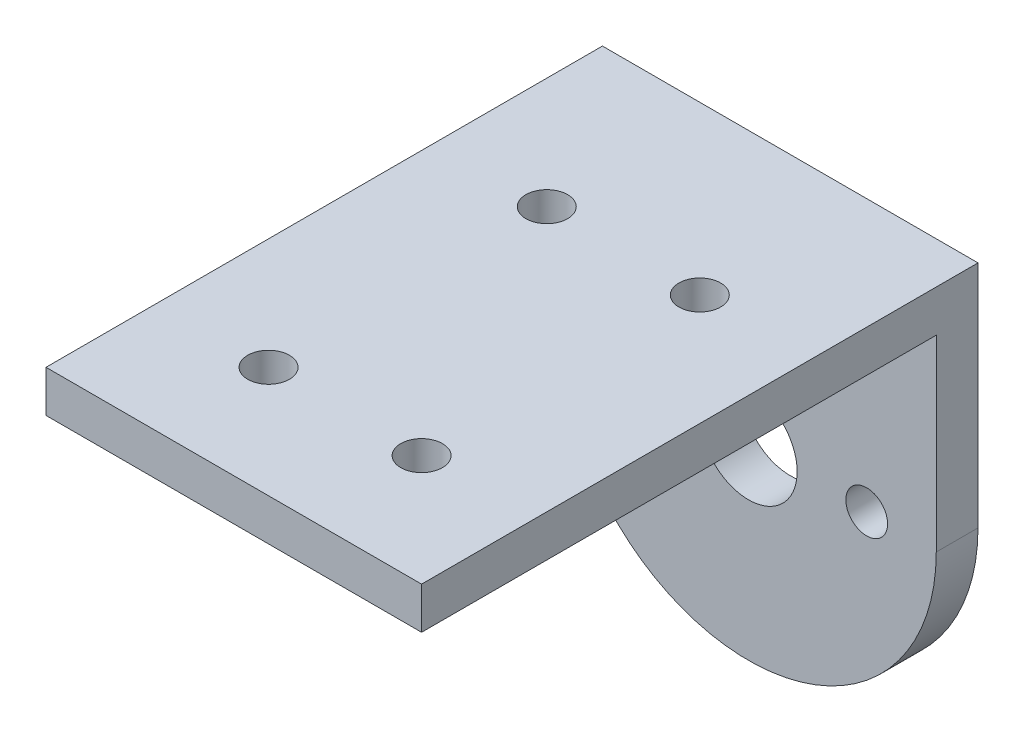
from build123d import *

# Parameters (mm, degrees)
MODEL_R             = 3.5
EXTRUDE_1_DEPTH     = 40
SKETCH_3_W          = 37
SKETCH_3_H          = 37
CUT_EXTRUDE_1_DEPTH = 40
SKETCH_4_R          = 1.5
CUT_EXTRUDE_2_DEPTH = 40
CUT_EXTRUDE1_REACH  = 42
SKETCH2_R           = 1.5


with BuildPart() as part:
    # Model → 凸台-拉伸1 (new body)
    with BuildSketch(Plane.XY):
        with BuildLine():
            Line((2619.766714505, 1592.826425633), (2619.766714505, 1609.326425633))
            Line((2619.766714505, 1609.326425633), (2592.766714505, 1609.326425633))
            Line((2592.766714505, 1609.326425633), (2592.766714505, 1592.826425633))
            ThreePointArc((2592.766714505, 1592.826425633), (2606.266714505, 1579.326425633), (2619.766714505, 1592.826425633))
        make_face()
        with Locations((2606.266714505, 1592.826425633)):
            Circle(MODEL_R, mode=Mode.SUBTRACT)
    extrude(amount=EXTRUDE_1_DEPTH)

    # 草图3 → 切除-拉伸1 (cut)
    with BuildSketch(Plane(origin=(2619.766714505, 0, 0), x_dir=(0, 0, -1), z_dir=(1, 0, 0))):
        with Locations((-21.5, 1587.826425633)):
            Rectangle(SKETCH_3_W, SKETCH_3_H)
    extrude(amount=-CUT_EXTRUDE_1_DEPTH, mode=Mode.SUBTRACT)

    # 草图4 → 切除-拉伸2 (cut)
    with BuildSketch(Plane(origin=(0, 1609.326425633, 0), x_dir=(1, 0, 0), z_dir=(0, 1, 0))):
        with Locations((2600.766714505, -32)):
            Circle(SKETCH_4_R)
        with Locations((2611.766714505, -32)):
            Circle(SKETCH_4_R)
        with Locations((2600.766714505, -12)):
            Circle(SKETCH_4_R)
        with Locations((2611.766714505, -12)):
            Circle(SKETCH_4_R)
    extrude(amount=-CUT_EXTRUDE_2_DEPTH, mode=Mode.SUBTRACT)

    # Sketch2 → Cut-Extrude1 (cut, up to next)
    with BuildSketch(Plane(origin=(0, 0, 0), x_dir=(-1, 0, 0), z_dir=(0, 0, -1)), mode=Mode.PRIVATE) as cut_extrude1_sk1:
        with Locations((-2597.766714505, 1592.826425633)):
            Circle(SKETCH2_R)
    cut_extrude1_tool1 = extrude(cut_extrude1_sk1.sketch, amount=-CUT_EXTRUDE1_REACH, mode=Mode.PRIVATE) & part.part
    add(cut_extrude1_tool1.solids().sort_by_distance((2597.766715, 1592.826426, 0))[0], mode=Mode.SUBTRACT)
    # Sketch2 → Cut-Extrude1 (cut, up to next)
    with BuildSketch(Plane(origin=(0, 0, 0), x_dir=(-1, 0, 0), z_dir=(0, 0, -1)), mode=Mode.PRIVATE) as cut_extrude1_sk2:
        with Locations((-2614.766714505, 1592.826425633)):
            Circle(SKETCH2_R)
    cut_extrude1_tool2 = extrude(cut_extrude1_sk2.sketch, amount=-CUT_EXTRUDE1_REACH, mode=Mode.PRIVATE) & part.part
    add(cut_extrude1_tool2.solids().sort_by_distance((2614.766715, 1592.826426, 0))[0], mode=Mode.SUBTRACT)


solid = part.part
